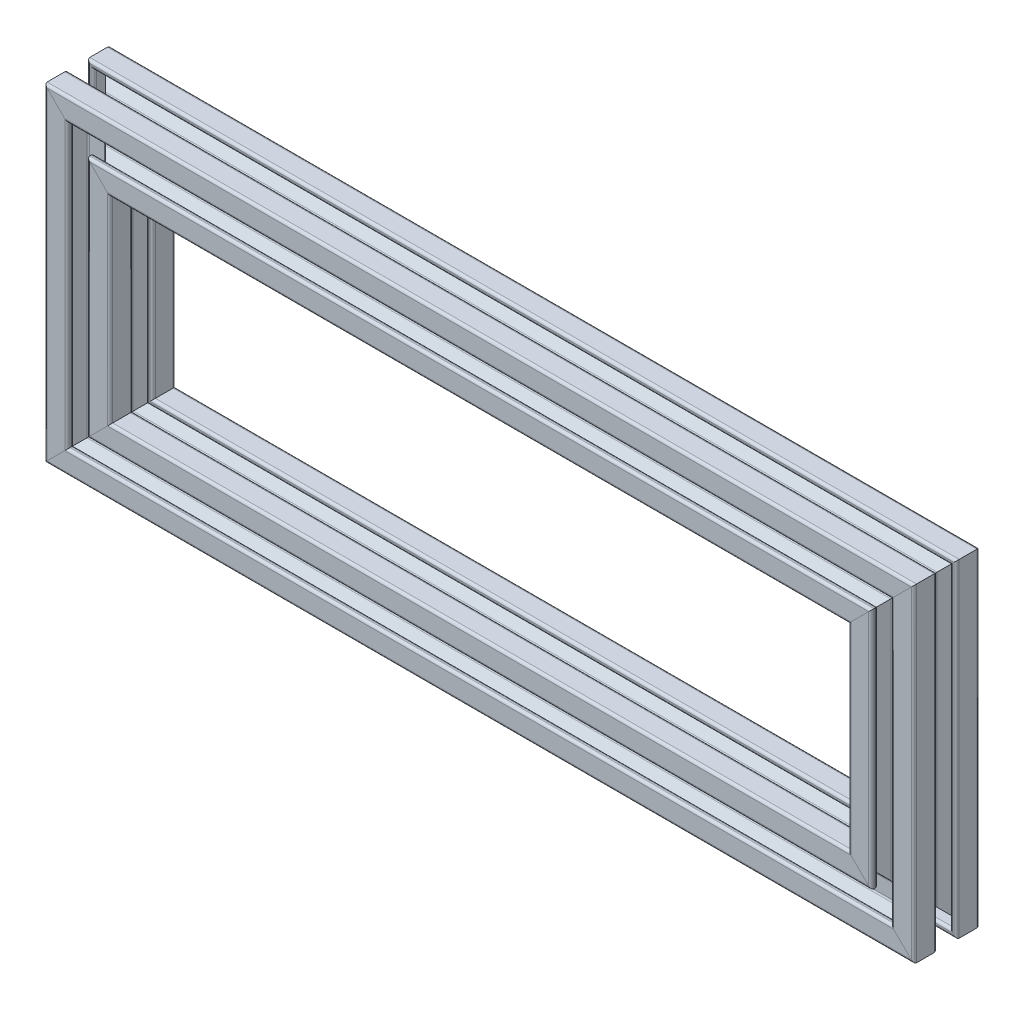
from build123d import *

# Parameters (mm, degrees)
SKETCH1_R               = 2
PROFILE_4X4_1_DEPTH     = 245
SKETCH1_ON_SEGMENT_2_R  = 2
PROFILE_4X4_1_2_DEPTH   = 245
SKETCH11_R              = 2
PROFILE_4X4_2_DEPTH     = 80
SKETCH11_ON_SEGMENT_2_R = 2
PROFILE_4X4_2_2_DEPTH   = 80
BODY_3_RUN_ON_DEPTH     = 10
BODY_2_RUN_ON_DEPTH     = 10
BODY_START              = 80
BODY_3_RUN_ON_2_DEPTH   = 10
PART_RUN_ON_DEPTH       = 10
PART_START              = 245
PART_RUN_ON_2_DEPTH     = 10
BODY_4_RUN_ON_DEPTH     = 10
BODY_START_2            = 245
BODY_2_RUN_ON_2_DEPTH   = 10
BODY_4_RUN_ON_2_DEPTH   = 10


with BuildPart() as part:
    # Sketch1 → Profile 4X4(1) (new body)
    with BuildSketch(Plane(origin=(-122.5, 40, 0), x_dir=(0, 1, 0), z_dir=(1, 0, 0))):
        with BuildLine():
            Line((-3, 9.2), (-3, 8.8))
            ThreePointArc((-3, 8.8), (-3.234314575, 8.234314575), (-3.8, 8))
            Line((-3.8, 8), (-6.585786438, 8))
            Line((-6.585786438, 8), (-2.820101013, 4.234314575))
            ThreePointArc((-2.820101013, 4.234314575), (-2.560562334, 4.060896374), (-2.254415588, 4))
            Line((-2.254415588, 4), (2.254415588, 4))
            ThreePointArc((2.254415588, 4), (2.560562334, 4.060896374), (2.820101013, 4.234314575))
            Line((2.820101013, 4.234314575), (6.585786438, 8))
            Line((6.585786438, 8), (3.8, 8))
            ThreePointArc((3.8, 8), (3.234314575, 8.234314575), (3, 8.8))
            Line((3, 8.8), (3, 9.2))
            ThreePointArc((3, 9.2), (3.234314575, 9.765685425), (3.8, 10))
            Line((3.8, 10), (9.2, 10))
            ThreePointArc((9.2, 10), (9.765685425, 9.765685425), (10, 9.2))
            Line((10, 9.2), (10, 3.8))
            ThreePointArc((10, 3.8), (9.765685425, 3.234314575), (9.2, 3))
            Line((9.2, 3), (8.8, 3))
            ThreePointArc((8.8, 3), (8.234314575, 3.234314575), (8, 3.8))
            Line((8, 3.8), (8, 6.585786438))
            Line((8, 6.585786438), (4.234314575, 2.820101013))
            ThreePointArc((4.234314575, 2.820101013), (4.060896374, 2.560562334), (4, 2.254415588))
            Line((4, 2.254415588), (4, -2.254415588))
            ThreePointArc((4, -2.254415588), (4.060896374, -2.560562334), (4.234314575, -2.820101013))
            Line((4.234314575, -2.820101013), (8, -6.585786438))
            Line((8, -6.585786438), (8, -3.8))
            ThreePointArc((8, -3.8), (8.234314575, -3.234314575), (8.8, -3))
            Line((8.8, -3), (9.2, -3))
            ThreePointArc((9.2, -3), (9.765685425, -3.234314575), (10, -3.8))
            Line((10, -3.8), (10, -9.2))
            ThreePointArc((10, -9.2), (9.765685425, -9.765685425), (9.2, -10))
            Line((9.2, -10), (3.8, -10))
            ThreePointArc((3.8, -10), (3.234314575, -9.765685425), (3, -9.2))
            Line((3, -9.2), (3, -8.8))
            ThreePointArc((3, -8.8), (3.234314575, -8.234314575), (3.8, -8))
            Line((3.8, -8), (6.585786438, -8))
            Line((6.585786438, -8), (2.820101013, -4.234314575))
            ThreePointArc((2.820101013, -4.234314575), (2.560562334, -4.060896374), (2.254415588, -4))
            Line((2.254415588, -4), (-2.254415588, -4))
            ThreePointArc((-2.254415588, -4), (-2.560562334, -4.060896374), (-2.820101013, -4.234314575))
            Line((-2.820101013, -4.234314575), (-6.585786438, -8))
            Line((-6.585786438, -8), (-3.8, -8))
            ThreePointArc((-3.8, -8), (-3.234314575, -8.234314575), (-3, -8.8))
            Line((-3, -8.8), (-3, -9.2))
            ThreePointArc((-3, -9.2), (-3.234314575, -9.765685425), (-3.8, -10))
            Line((-3.8, -10), (-9.2, -10))
            ThreePointArc((-9.2, -10), (-9.765685425, -9.765685425), (-10, -9.2))
            Line((-10, -9.2), (-10, -3.8))
            ThreePointArc((-10, -3.8), (-9.765685425, -3.234314575), (-9.2, -3))
            Line((-9.2, -3), (-8.8, -3))
            ThreePointArc((-8.8, -3), (-8.234314575, -3.234314575), (-8, -3.8))
            Line((-8, -3.8), (-8, -6.585786438))
            Line((-8, -6.585786438), (-4.234314575, -2.820101013))
            ThreePointArc((-4.234314575, -2.820101013), (-4.060896374, -2.560562334), (-4, -2.254415588))
            Line((-4, -2.254415588), (-4, 2.254415588))
            ThreePointArc((-4, 2.254415588), (-4.060896374, 2.560562334), (-4.234314575, 2.820101013))
            Line((-4.234314575, 2.820101013), (-8, 6.585786438))
            Line((-8, 6.585786438), (-8, 3.8))
            ThreePointArc((-8, 3.8), (-8.234314575, 3.234314575), (-8.8, 3))
            Line((-8.8, 3), (-9.2, 3))
            ThreePointArc((-9.2, 3), (-9.765685425, 3.234314575), (-10, 3.8))
            Line((-10, 3.8), (-10, 9.2))
            ThreePointArc((-10, 9.2), (-9.765685425, 9.765685425), (-9.2, 10))
            Line((-9.2, 10), (-3.8, 10))
            ThreePointArc((-3.8, 10), (-3.234314575, 9.765685425), (-3, 9.2))
        make_face()
        Circle(SKETCH1_R, mode=Mode.SUBTRACT)
    extrude(amount=PROFILE_4X4_1_DEPTH)

    # Sketch1 → part run on (add)
    with BuildSketch(Plane(origin=(-122.5, 40, 0), x_dir=(0, 1, 0), z_dir=(1, 0, 0))):
        with BuildLine():
            Line((-3, 9.2), (-3, 8.8))
            ThreePointArc((-3, 8.8), (-3.234314575, 8.234314575), (-3.8, 8))
            Line((-3.8, 8), (-6.585786438, 8))
            Line((-6.585786438, 8), (-2.820101013, 4.234314575))
            ThreePointArc((-2.820101013, 4.234314575), (-2.560562334, 4.060896374), (-2.254415588, 4))
            Line((-2.254415588, 4), (2.254415588, 4))
            ThreePointArc((2.254415588, 4), (2.560562334, 4.060896374), (2.820101013, 4.234314575))
            Line((2.820101013, 4.234314575), (6.585786438, 8))
            Line((6.585786438, 8), (3.8, 8))
            ThreePointArc((3.8, 8), (3.234314575, 8.234314575), (3, 8.8))
            Line((3, 8.8), (3, 9.2))
            ThreePointArc((3, 9.2), (3.234314575, 9.765685425), (3.8, 10))
            Line((3.8, 10), (9.2, 10))
            ThreePointArc((9.2, 10), (9.765685425, 9.765685425), (10, 9.2))
            Line((10, 9.2), (10, 3.8))
            ThreePointArc((10, 3.8), (9.765685425, 3.234314575), (9.2, 3))
            Line((9.2, 3), (8.8, 3))
            ThreePointArc((8.8, 3), (8.234314575, 3.234314575), (8, 3.8))
            Line((8, 3.8), (8, 6.585786438))
            Line((8, 6.585786438), (4.234314575, 2.820101013))
            ThreePointArc((4.234314575, 2.820101013), (4.060896374, 2.560562334), (4, 2.254415588))
            Line((4, 2.254415588), (4, -2.254415588))
            ThreePointArc((4, -2.254415588), (4.060896374, -2.560562334), (4.234314575, -2.820101013))
            Line((4.234314575, -2.820101013), (8, -6.585786438))
            Line((8, -6.585786438), (8, -3.8))
            ThreePointArc((8, -3.8), (8.234314575, -3.234314575), (8.8, -3))
            Line((8.8, -3), (9.2, -3))
            ThreePointArc((9.2, -3), (9.765685425, -3.234314575), (10, -3.8))
            Line((10, -3.8), (10, -9.2))
            ThreePointArc((10, -9.2), (9.765685425, -9.765685425), (9.2, -10))
            Line((9.2, -10), (3.8, -10))
            ThreePointArc((3.8, -10), (3.234314575, -9.765685425), (3, -9.2))
            Line((3, -9.2), (3, -8.8))
            ThreePointArc((3, -8.8), (3.234314575, -8.234314575), (3.8, -8))
            Line((3.8, -8), (6.585786438, -8))
            Line((6.585786438, -8), (2.820101013, -4.234314575))
            ThreePointArc((2.820101013, -4.234314575), (2.560562334, -4.060896374), (2.254415588, -4))
            Line((2.254415588, -4), (-2.254415588, -4))
            ThreePointArc((-2.254415588, -4), (-2.560562334, -4.060896374), (-2.820101013, -4.234314575))
            Line((-2.820101013, -4.234314575), (-6.585786438, -8))
            Line((-6.585786438, -8), (-3.8, -8))
            ThreePointArc((-3.8, -8), (-3.234314575, -8.234314575), (-3, -8.8))
            Line((-3, -8.8), (-3, -9.2))
            ThreePointArc((-3, -9.2), (-3.234314575, -9.765685425), (-3.8, -10))
            Line((-3.8, -10), (-9.2, -10))
            ThreePointArc((-9.2, -10), (-9.765685425, -9.765685425), (-10, -9.2))
            Line((-10, -9.2), (-10, -3.8))
            ThreePointArc((-10, -3.8), (-9.765685425, -3.234314575), (-9.2, -3))
            Line((-9.2, -3), (-8.8, -3))
            ThreePointArc((-8.8, -3), (-8.234314575, -3.234314575), (-8, -3.8))
            Line((-8, -3.8), (-8, -6.585786438))
            Line((-8, -6.585786438), (-4.234314575, -2.820101013))
            ThreePointArc((-4.234314575, -2.820101013), (-4.060896374, -2.560562334), (-4, -2.254415588))
            Line((-4, -2.254415588), (-4, 2.254415588))
            ThreePointArc((-4, 2.254415588), (-4.060896374, 2.560562334), (-4.234314575, 2.820101013))
            Line((-4.234314575, 2.820101013), (-8, 6.585786438))
            Line((-8, 6.585786438), (-8, 3.8))
            ThreePointArc((-8, 3.8), (-8.234314575, 3.234314575), (-8.8, 3))
            Line((-8.8, 3), (-9.2, 3))
            ThreePointArc((-9.2, 3), (-9.765685425, 3.234314575), (-10, 3.8))
            Line((-10, 3.8), (-10, 9.2))
            ThreePointArc((-10, 9.2), (-9.765685425, 9.765685425), (-9.2, 10))
            Line((-9.2, 10), (-3.8, 10))
            ThreePointArc((-3.8, 10), (-3.234314575, 9.765685425), (-3, 9.2))
        make_face()
        Circle(SKETCH1_R, mode=Mode.SUBTRACT)
    extrude(amount=-PART_RUN_ON_DEPTH)

    # Trim/Extend2
    split(bisect_by=Plane(origin=(-122.5, 40, 0), x_dir=(-0.707106781, 0.707106781, 0), z_dir=(0.707106781, 0.707106781, 0)), keep=Keep.TOP)

    # Sketch1 → part run on 2 (add)
    with BuildSketch(Plane(origin=(-122.5, 40, 0), x_dir=(0, 1, 0), z_dir=(1, 0, 0)).offset(PART_START)):
        with BuildLine():
            Line((-3, 9.2), (-3, 8.8))
            ThreePointArc((-3, 8.8), (-3.234314575, 8.234314575), (-3.8, 8))
            Line((-3.8, 8), (-6.585786438, 8))
            Line((-6.585786438, 8), (-2.820101013, 4.234314575))
            ThreePointArc((-2.820101013, 4.234314575), (-2.560562334, 4.060896374), (-2.254415588, 4))
            Line((-2.254415588, 4), (2.254415588, 4))
            ThreePointArc((2.254415588, 4), (2.560562334, 4.060896374), (2.820101013, 4.234314575))
            Line((2.820101013, 4.234314575), (6.585786438, 8))
            Line((6.585786438, 8), (3.8, 8))
            ThreePointArc((3.8, 8), (3.234314575, 8.234314575), (3, 8.8))
            Line((3, 8.8), (3, 9.2))
            ThreePointArc((3, 9.2), (3.234314575, 9.765685425), (3.8, 10))
            Line((3.8, 10), (9.2, 10))
            ThreePointArc((9.2, 10), (9.765685425, 9.765685425), (10, 9.2))
            Line((10, 9.2), (10, 3.8))
            ThreePointArc((10, 3.8), (9.765685425, 3.234314575), (9.2, 3))
            Line((9.2, 3), (8.8, 3))
            ThreePointArc((8.8, 3), (8.234314575, 3.234314575), (8, 3.8))
            Line((8, 3.8), (8, 6.585786438))
            Line((8, 6.585786438), (4.234314575, 2.820101013))
            ThreePointArc((4.234314575, 2.820101013), (4.060896374, 2.560562334), (4, 2.254415588))
            Line((4, 2.254415588), (4, -2.254415588))
            ThreePointArc((4, -2.254415588), (4.060896374, -2.560562334), (4.234314575, -2.820101013))
            Line((4.234314575, -2.820101013), (8, -6.585786438))
            Line((8, -6.585786438), (8, -3.8))
            ThreePointArc((8, -3.8), (8.234314575, -3.234314575), (8.8, -3))
            Line((8.8, -3), (9.2, -3))
            ThreePointArc((9.2, -3), (9.765685425, -3.234314575), (10, -3.8))
            Line((10, -3.8), (10, -9.2))
            ThreePointArc((10, -9.2), (9.765685425, -9.765685425), (9.2, -10))
            Line((9.2, -10), (3.8, -10))
            ThreePointArc((3.8, -10), (3.234314575, -9.765685425), (3, -9.2))
            Line((3, -9.2), (3, -8.8))
            ThreePointArc((3, -8.8), (3.234314575, -8.234314575), (3.8, -8))
            Line((3.8, -8), (6.585786438, -8))
            Line((6.585786438, -8), (2.820101013, -4.234314575))
            ThreePointArc((2.820101013, -4.234314575), (2.560562334, -4.060896374), (2.254415588, -4))
            Line((2.254415588, -4), (-2.254415588, -4))
            ThreePointArc((-2.254415588, -4), (-2.560562334, -4.060896374), (-2.820101013, -4.234314575))
            Line((-2.820101013, -4.234314575), (-6.585786438, -8))
            Line((-6.585786438, -8), (-3.8, -8))
            ThreePointArc((-3.8, -8), (-3.234314575, -8.234314575), (-3, -8.8))
            Line((-3, -8.8), (-3, -9.2))
            ThreePointArc((-3, -9.2), (-3.234314575, -9.765685425), (-3.8, -10))
            Line((-3.8, -10), (-9.2, -10))
            ThreePointArc((-9.2, -10), (-9.765685425, -9.765685425), (-10, -9.2))
            Line((-10, -9.2), (-10, -3.8))
            ThreePointArc((-10, -3.8), (-9.765685425, -3.234314575), (-9.2, -3))
            Line((-9.2, -3), (-8.8, -3))
            ThreePointArc((-8.8, -3), (-8.234314575, -3.234314575), (-8, -3.8))
            Line((-8, -3.8), (-8, -6.585786438))
            Line((-8, -6.585786438), (-4.234314575, -2.820101013))
            ThreePointArc((-4.234314575, -2.820101013), (-4.060896374, -2.560562334), (-4, -2.254415588))
            Line((-4, -2.254415588), (-4, 2.254415588))
            ThreePointArc((-4, 2.254415588), (-4.060896374, 2.560562334), (-4.234314575, 2.820101013))
            Line((-4.234314575, 2.820101013), (-8, 6.585786438))
            Line((-8, 6.585786438), (-8, 3.8))
            ThreePointArc((-8, 3.8), (-8.234314575, 3.234314575), (-8.8, 3))
            Line((-8.8, 3), (-9.2, 3))
            ThreePointArc((-9.2, 3), (-9.765685425, 3.234314575), (-10, 3.8))
            Line((-10, 3.8), (-10, 9.2))
            ThreePointArc((-10, 9.2), (-9.765685425, 9.765685425), (-9.2, 10))
            Line((-9.2, 10), (-3.8, 10))
            ThreePointArc((-3.8, 10), (-3.234314575, 9.765685425), (-3, 9.2))
        make_face()
        Circle(SKETCH1_R, mode=Mode.SUBTRACT)
    extrude(amount=PART_RUN_ON_2_DEPTH)

    # Trim/Extend3
    split(bisect_by=Plane(origin=(122.5, 40, 0), x_dir=(-0.707106781, -0.707106781, 0), z_dir=(-0.707106781, 0.707106781, 0)), keep=Keep.TOP)


with BuildPart() as body_2:
    # Sketch1 on segment 2 (carried to segment 2) → Profile 4X4_1 2 (new body)
    with BuildSketch(Plane(origin=(-122.5, -40, 0), x_dir=(0, 1, 0), z_dir=(1, 0, 0))):
        with BuildLine():
            Line((-3, 9.2), (-3, 8.8))
            ThreePointArc((-3, 8.8), (-3.234314575, 8.234314575), (-3.8, 8))
            Line((-3.8, 8), (-6.585786438, 8))
            Line((-6.585786438, 8), (-2.820101013, 4.234314575))
            ThreePointArc((-2.820101013, 4.234314575), (-2.560562334, 4.060896374), (-2.254415588, 4))
            Line((-2.254415588, 4), (2.254415588, 4))
            ThreePointArc((2.254415588, 4), (2.560562334, 4.060896374), (2.820101013, 4.234314575))
            Line((2.820101013, 4.234314575), (6.585786438, 8))
            Line((6.585786438, 8), (3.8, 8))
            ThreePointArc((3.8, 8), (3.234314575, 8.234314575), (3, 8.8))
            Line((3, 8.8), (3, 9.2))
            ThreePointArc((3, 9.2), (3.234314575, 9.765685425), (3.8, 10))
            Line((3.8, 10), (9.2, 10))
            ThreePointArc((9.2, 10), (9.765685425, 9.765685425), (10, 9.2))
            Line((10, 9.2), (10, 3.8))
            ThreePointArc((10, 3.8), (9.765685425, 3.234314575), (9.2, 3))
            Line((9.2, 3), (8.8, 3))
            ThreePointArc((8.8, 3), (8.234314575, 3.234314575), (8, 3.8))
            Line((8, 3.8), (8, 6.585786438))
            Line((8, 6.585786438), (4.234314575, 2.820101013))
            ThreePointArc((4.234314575, 2.820101013), (4.060896374, 2.560562334), (4, 2.254415588))
            Line((4, 2.254415588), (4, -2.254415588))
            ThreePointArc((4, -2.254415588), (4.060896374, -2.560562334), (4.234314575, -2.820101013))
            Line((4.234314575, -2.820101013), (8, -6.585786438))
            Line((8, -6.585786438), (8, -3.8))
            ThreePointArc((8, -3.8), (8.234314575, -3.234314575), (8.8, -3))
            Line((8.8, -3), (9.2, -3))
            ThreePointArc((9.2, -3), (9.765685425, -3.234314575), (10, -3.8))
            Line((10, -3.8), (10, -9.2))
            ThreePointArc((10, -9.2), (9.765685425, -9.765685425), (9.2, -10))
            Line((9.2, -10), (3.8, -10))
            ThreePointArc((3.8, -10), (3.234314575, -9.765685425), (3, -9.2))
            Line((3, -9.2), (3, -8.8))
            ThreePointArc((3, -8.8), (3.234314575, -8.234314575), (3.8, -8))
            Line((3.8, -8), (6.585786438, -8))
            Line((6.585786438, -8), (2.820101013, -4.234314575))
            ThreePointArc((2.820101013, -4.234314575), (2.560562334, -4.060896374), (2.254415588, -4))
            Line((2.254415588, -4), (-2.254415588, -4))
            ThreePointArc((-2.254415588, -4), (-2.560562334, -4.060896374), (-2.820101013, -4.234314575))
            Line((-2.820101013, -4.234314575), (-6.585786438, -8))
            Line((-6.585786438, -8), (-3.8, -8))
            ThreePointArc((-3.8, -8), (-3.234314575, -8.234314575), (-3, -8.8))
            Line((-3, -8.8), (-3, -9.2))
            ThreePointArc((-3, -9.2), (-3.234314575, -9.765685425), (-3.8, -10))
            Line((-3.8, -10), (-9.2, -10))
            ThreePointArc((-9.2, -10), (-9.765685425, -9.765685425), (-10, -9.2))
            Line((-10, -9.2), (-10, -3.8))
            ThreePointArc((-10, -3.8), (-9.765685425, -3.234314575), (-9.2, -3))
            Line((-9.2, -3), (-8.8, -3))
            ThreePointArc((-8.8, -3), (-8.234314575, -3.234314575), (-8, -3.8))
            Line((-8, -3.8), (-8, -6.585786438))
            Line((-8, -6.585786438), (-4.234314575, -2.820101013))
            ThreePointArc((-4.234314575, -2.820101013), (-4.060896374, -2.560562334), (-4, -2.254415588))
            Line((-4, -2.254415588), (-4, 2.254415588))
            ThreePointArc((-4, 2.254415588), (-4.060896374, 2.560562334), (-4.234314575, 2.820101013))
            Line((-4.234314575, 2.820101013), (-8, 6.585786438))
            Line((-8, 6.585786438), (-8, 3.8))
            ThreePointArc((-8, 3.8), (-8.234314575, 3.234314575), (-8.8, 3))
            Line((-8.8, 3), (-9.2, 3))
            ThreePointArc((-9.2, 3), (-9.765685425, 3.234314575), (-10, 3.8))
            Line((-10, 3.8), (-10, 9.2))
            ThreePointArc((-10, 9.2), (-9.765685425, 9.765685425), (-9.2, 10))
            Line((-9.2, 10), (-3.8, 10))
            ThreePointArc((-3.8, 10), (-3.234314575, 9.765685425), (-3, 9.2))
        make_face()
        Circle(SKETCH1_ON_SEGMENT_2_R, mode=Mode.SUBTRACT)
    extrude(amount=PROFILE_4X4_1_2_DEPTH)

    # Sketch1 on segment 2 (carried to segment 2) → body 2 run on (add)
    with BuildSketch(Plane(origin=(-122.5, -40, 0), x_dir=(0, 1, 0), z_dir=(1, 0, 0))):
        with BuildLine():
            Line((-3, 9.2), (-3, 8.8))
            ThreePointArc((-3, 8.8), (-3.234314575, 8.234314575), (-3.8, 8))
            Line((-3.8, 8), (-6.585786438, 8))
            Line((-6.585786438, 8), (-2.820101013, 4.234314575))
            ThreePointArc((-2.820101013, 4.234314575), (-2.560562334, 4.060896374), (-2.254415588, 4))
            Line((-2.254415588, 4), (2.254415588, 4))
            ThreePointArc((2.254415588, 4), (2.560562334, 4.060896374), (2.820101013, 4.234314575))
            Line((2.820101013, 4.234314575), (6.585786438, 8))
            Line((6.585786438, 8), (3.8, 8))
            ThreePointArc((3.8, 8), (3.234314575, 8.234314575), (3, 8.8))
            Line((3, 8.8), (3, 9.2))
            ThreePointArc((3, 9.2), (3.234314575, 9.765685425), (3.8, 10))
            Line((3.8, 10), (9.2, 10))
            ThreePointArc((9.2, 10), (9.765685425, 9.765685425), (10, 9.2))
            Line((10, 9.2), (10, 3.8))
            ThreePointArc((10, 3.8), (9.765685425, 3.234314575), (9.2, 3))
            Line((9.2, 3), (8.8, 3))
            ThreePointArc((8.8, 3), (8.234314575, 3.234314575), (8, 3.8))
            Line((8, 3.8), (8, 6.585786438))
            Line((8, 6.585786438), (4.234314575, 2.820101013))
            ThreePointArc((4.234314575, 2.820101013), (4.060896374, 2.560562334), (4, 2.254415588))
            Line((4, 2.254415588), (4, -2.254415588))
            ThreePointArc((4, -2.254415588), (4.060896374, -2.560562334), (4.234314575, -2.820101013))
            Line((4.234314575, -2.820101013), (8, -6.585786438))
            Line((8, -6.585786438), (8, -3.8))
            ThreePointArc((8, -3.8), (8.234314575, -3.234314575), (8.8, -3))
            Line((8.8, -3), (9.2, -3))
            ThreePointArc((9.2, -3), (9.765685425, -3.234314575), (10, -3.8))
            Line((10, -3.8), (10, -9.2))
            ThreePointArc((10, -9.2), (9.765685425, -9.765685425), (9.2, -10))
            Line((9.2, -10), (3.8, -10))
            ThreePointArc((3.8, -10), (3.234314575, -9.765685425), (3, -9.2))
            Line((3, -9.2), (3, -8.8))
            ThreePointArc((3, -8.8), (3.234314575, -8.234314575), (3.8, -8))
            Line((3.8, -8), (6.585786438, -8))
            Line((6.585786438, -8), (2.820101013, -4.234314575))
            ThreePointArc((2.820101013, -4.234314575), (2.560562334, -4.060896374), (2.254415588, -4))
            Line((2.254415588, -4), (-2.254415588, -4))
            ThreePointArc((-2.254415588, -4), (-2.560562334, -4.060896374), (-2.820101013, -4.234314575))
            Line((-2.820101013, -4.234314575), (-6.585786438, -8))
            Line((-6.585786438, -8), (-3.8, -8))
            ThreePointArc((-3.8, -8), (-3.234314575, -8.234314575), (-3, -8.8))
            Line((-3, -8.8), (-3, -9.2))
            ThreePointArc((-3, -9.2), (-3.234314575, -9.765685425), (-3.8, -10))
            Line((-3.8, -10), (-9.2, -10))
            ThreePointArc((-9.2, -10), (-9.765685425, -9.765685425), (-10, -9.2))
            Line((-10, -9.2), (-10, -3.8))
            ThreePointArc((-10, -3.8), (-9.765685425, -3.234314575), (-9.2, -3))
            Line((-9.2, -3), (-8.8, -3))
            ThreePointArc((-8.8, -3), (-8.234314575, -3.234314575), (-8, -3.8))
            Line((-8, -3.8), (-8, -6.585786438))
            Line((-8, -6.585786438), (-4.234314575, -2.820101013))
            ThreePointArc((-4.234314575, -2.820101013), (-4.060896374, -2.560562334), (-4, -2.254415588))
            Line((-4, -2.254415588), (-4, 2.254415588))
            ThreePointArc((-4, 2.254415588), (-4.060896374, 2.560562334), (-4.234314575, 2.820101013))
            Line((-4.234314575, 2.820101013), (-8, 6.585786438))
            Line((-8, 6.585786438), (-8, 3.8))
            ThreePointArc((-8, 3.8), (-8.234314575, 3.234314575), (-8.8, 3))
            Line((-8.8, 3), (-9.2, 3))
            ThreePointArc((-9.2, 3), (-9.765685425, 3.234314575), (-10, 3.8))
            Line((-10, 3.8), (-10, 9.2))
            ThreePointArc((-10, 9.2), (-9.765685425, 9.765685425), (-9.2, 10))
            Line((-9.2, 10), (-3.8, 10))
            ThreePointArc((-3.8, 10), (-3.234314575, 9.765685425), (-3, 9.2))
        make_face()
        Circle(SKETCH1_ON_SEGMENT_2_R, mode=Mode.SUBTRACT)
    extrude(amount=-BODY_2_RUN_ON_DEPTH)

    # Trim/Extend1
    split(bisect_by=Plane(origin=(-122.5, -40, 0), x_dir=(0.707106781, 0.707106781, 0), z_dir=(0.707106781, -0.707106781, 0)), keep=Keep.TOP)

    # Sketch1 on segment 2 (carried to segment 2) → body 2 run on 2 (add)
    with BuildSketch(Plane(origin=(-122.5, -40, 0), x_dir=(0, 1, 0), z_dir=(1, 0, 0)).offset(BODY_START_2)):
        with BuildLine():
            Line((-3, 9.2), (-3, 8.8))
            ThreePointArc((-3, 8.8), (-3.234314575, 8.234314575), (-3.8, 8))
            Line((-3.8, 8), (-6.585786438, 8))
            Line((-6.585786438, 8), (-2.820101013, 4.234314575))
            ThreePointArc((-2.820101013, 4.234314575), (-2.560562334, 4.060896374), (-2.254415588, 4))
            Line((-2.254415588, 4), (2.254415588, 4))
            ThreePointArc((2.254415588, 4), (2.560562334, 4.060896374), (2.820101013, 4.234314575))
            Line((2.820101013, 4.234314575), (6.585786438, 8))
            Line((6.585786438, 8), (3.8, 8))
            ThreePointArc((3.8, 8), (3.234314575, 8.234314575), (3, 8.8))
            Line((3, 8.8), (3, 9.2))
            ThreePointArc((3, 9.2), (3.234314575, 9.765685425), (3.8, 10))
            Line((3.8, 10), (9.2, 10))
            ThreePointArc((9.2, 10), (9.765685425, 9.765685425), (10, 9.2))
            Line((10, 9.2), (10, 3.8))
            ThreePointArc((10, 3.8), (9.765685425, 3.234314575), (9.2, 3))
            Line((9.2, 3), (8.8, 3))
            ThreePointArc((8.8, 3), (8.234314575, 3.234314575), (8, 3.8))
            Line((8, 3.8), (8, 6.585786438))
            Line((8, 6.585786438), (4.234314575, 2.820101013))
            ThreePointArc((4.234314575, 2.820101013), (4.060896374, 2.560562334), (4, 2.254415588))
            Line((4, 2.254415588), (4, -2.254415588))
            ThreePointArc((4, -2.254415588), (4.060896374, -2.560562334), (4.234314575, -2.820101013))
            Line((4.234314575, -2.820101013), (8, -6.585786438))
            Line((8, -6.585786438), (8, -3.8))
            ThreePointArc((8, -3.8), (8.234314575, -3.234314575), (8.8, -3))
            Line((8.8, -3), (9.2, -3))
            ThreePointArc((9.2, -3), (9.765685425, -3.234314575), (10, -3.8))
            Line((10, -3.8), (10, -9.2))
            ThreePointArc((10, -9.2), (9.765685425, -9.765685425), (9.2, -10))
            Line((9.2, -10), (3.8, -10))
            ThreePointArc((3.8, -10), (3.234314575, -9.765685425), (3, -9.2))
            Line((3, -9.2), (3, -8.8))
            ThreePointArc((3, -8.8), (3.234314575, -8.234314575), (3.8, -8))
            Line((3.8, -8), (6.585786438, -8))
            Line((6.585786438, -8), (2.820101013, -4.234314575))
            ThreePointArc((2.820101013, -4.234314575), (2.560562334, -4.060896374), (2.254415588, -4))
            Line((2.254415588, -4), (-2.254415588, -4))
            ThreePointArc((-2.254415588, -4), (-2.560562334, -4.060896374), (-2.820101013, -4.234314575))
            Line((-2.820101013, -4.234314575), (-6.585786438, -8))
            Line((-6.585786438, -8), (-3.8, -8))
            ThreePointArc((-3.8, -8), (-3.234314575, -8.234314575), (-3, -8.8))
            Line((-3, -8.8), (-3, -9.2))
            ThreePointArc((-3, -9.2), (-3.234314575, -9.765685425), (-3.8, -10))
            Line((-3.8, -10), (-9.2, -10))
            ThreePointArc((-9.2, -10), (-9.765685425, -9.765685425), (-10, -9.2))
            Line((-10, -9.2), (-10, -3.8))
            ThreePointArc((-10, -3.8), (-9.765685425, -3.234314575), (-9.2, -3))
            Line((-9.2, -3), (-8.8, -3))
            ThreePointArc((-8.8, -3), (-8.234314575, -3.234314575), (-8, -3.8))
            Line((-8, -3.8), (-8, -6.585786438))
            Line((-8, -6.585786438), (-4.234314575, -2.820101013))
            ThreePointArc((-4.234314575, -2.820101013), (-4.060896374, -2.560562334), (-4, -2.254415588))
            Line((-4, -2.254415588), (-4, 2.254415588))
            ThreePointArc((-4, 2.254415588), (-4.060896374, 2.560562334), (-4.234314575, 2.820101013))
            Line((-4.234314575, 2.820101013), (-8, 6.585786438))
            Line((-8, 6.585786438), (-8, 3.8))
            ThreePointArc((-8, 3.8), (-8.234314575, 3.234314575), (-8.8, 3))
            Line((-8.8, 3), (-9.2, 3))
            ThreePointArc((-9.2, 3), (-9.765685425, 3.234314575), (-10, 3.8))
            Line((-10, 3.8), (-10, 9.2))
            ThreePointArc((-10, 9.2), (-9.765685425, 9.765685425), (-9.2, 10))
            Line((-9.2, 10), (-3.8, 10))
            ThreePointArc((-3.8, 10), (-3.234314575, 9.765685425), (-3, 9.2))
        make_face()
        Circle(SKETCH1_ON_SEGMENT_2_R, mode=Mode.SUBTRACT)
    extrude(amount=BODY_2_RUN_ON_2_DEPTH)

    # Trim/Extend4
    split(bisect_by=Plane(origin=(122.5, -40, 0), x_dir=(0.707106781, -0.707106781, 0), z_dir=(-0.707106781, -0.707106781, 0)), keep=Keep.TOP)


with BuildPart() as body_3:
    # Sketch11 → Profile 4X4(2) (new body)
    with BuildSketch(Plane(origin=(-122.5, -40, 0), x_dir=(-1, 0, 0), z_dir=(0, 1, 0))):
        with BuildLine():
            Line((-3, 9.2), (-3, 8.8))
            ThreePointArc((-3, 8.8), (-3.234314575, 8.234314575), (-3.8, 8))
            Line((-3.8, 8), (-6.585786438, 8))
            Line((-6.585786438, 8), (-2.820101013, 4.234314575))
            ThreePointArc((-2.820101013, 4.234314575), (-2.560562334, 4.060896374), (-2.254415588, 4))
            Line((-2.254415588, 4), (2.254415588, 4))
            ThreePointArc((2.254415588, 4), (2.560562334, 4.060896374), (2.820101013, 4.234314575))
            Line((2.820101013, 4.234314575), (6.585786438, 8))
            Line((6.585786438, 8), (3.8, 8))
            ThreePointArc((3.8, 8), (3.234314575, 8.234314575), (3, 8.8))
            Line((3, 8.8), (3, 9.2))
            ThreePointArc((3, 9.2), (3.234314575, 9.765685425), (3.8, 10))
            Line((3.8, 10), (9.2, 10))
            ThreePointArc((9.2, 10), (9.765685425, 9.765685425), (10, 9.2))
            Line((10, 9.2), (10, 3.8))
            ThreePointArc((10, 3.8), (9.765685425, 3.234314575), (9.2, 3))
            Line((9.2, 3), (8.8, 3))
            ThreePointArc((8.8, 3), (8.234314575, 3.234314575), (8, 3.8))
            Line((8, 3.8), (8, 6.585786438))
            Line((8, 6.585786438), (4.234314575, 2.820101013))
            ThreePointArc((4.234314575, 2.820101013), (4.060896374, 2.560562334), (4, 2.254415588))
            Line((4, 2.254415588), (4, -2.254415588))
            ThreePointArc((4, -2.254415588), (4.060896374, -2.560562334), (4.234314575, -2.820101013))
            Line((4.234314575, -2.820101013), (8, -6.585786438))
            Line((8, -6.585786438), (8, -3.8))
            ThreePointArc((8, -3.8), (8.234314575, -3.234314575), (8.8, -3))
            Line((8.8, -3), (9.2, -3))
            ThreePointArc((9.2, -3), (9.765685425, -3.234314575), (10, -3.8))
            Line((10, -3.8), (10, -9.2))
            ThreePointArc((10, -9.2), (9.765685425, -9.765685425), (9.2, -10))
            Line((9.2, -10), (3.8, -10))
            ThreePointArc((3.8, -10), (3.234314575, -9.765685425), (3, -9.2))
            Line((3, -9.2), (3, -8.8))
            ThreePointArc((3, -8.8), (3.234314575, -8.234314575), (3.8, -8))
            Line((3.8, -8), (6.585786438, -8))
            Line((6.585786438, -8), (2.820101013, -4.234314575))
            ThreePointArc((2.820101013, -4.234314575), (2.560562334, -4.060896374), (2.254415588, -4))
            Line((2.254415588, -4), (-2.254415588, -4))
            ThreePointArc((-2.254415588, -4), (-2.560562334, -4.060896374), (-2.820101013, -4.234314575))
            Line((-2.820101013, -4.234314575), (-6.585786438, -8))
            Line((-6.585786438, -8), (-3.8, -8))
            ThreePointArc((-3.8, -8), (-3.234314575, -8.234314575), (-3, -8.8))
            Line((-3, -8.8), (-3, -9.2))
            ThreePointArc((-3, -9.2), (-3.234314575, -9.765685425), (-3.8, -10))
            Line((-3.8, -10), (-9.2, -10))
            ThreePointArc((-9.2, -10), (-9.765685425, -9.765685425), (-10, -9.2))
            Line((-10, -9.2), (-10, -3.8))
            ThreePointArc((-10, -3.8), (-9.765685425, -3.234314575), (-9.2, -3))
            Line((-9.2, -3), (-8.8, -3))
            ThreePointArc((-8.8, -3), (-8.234314575, -3.234314575), (-8, -3.8))
            Line((-8, -3.8), (-8, -6.585786438))
            Line((-8, -6.585786438), (-4.234314575, -2.820101013))
            ThreePointArc((-4.234314575, -2.820101013), (-4.060896374, -2.560562334), (-4, -2.254415588))
            Line((-4, -2.254415588), (-4, 2.254415588))
            ThreePointArc((-4, 2.254415588), (-4.060896374, 2.560562334), (-4.234314575, 2.820101013))
            Line((-4.234314575, 2.820101013), (-8, 6.585786438))
            Line((-8, 6.585786438), (-8, 3.8))
            ThreePointArc((-8, 3.8), (-8.234314575, 3.234314575), (-8.8, 3))
            Line((-8.8, 3), (-9.2, 3))
            ThreePointArc((-9.2, 3), (-9.765685425, 3.234314575), (-10, 3.8))
            Line((-10, 3.8), (-10, 9.2))
            ThreePointArc((-10, 9.2), (-9.765685425, 9.765685425), (-9.2, 10))
            Line((-9.2, 10), (-3.8, 10))
            ThreePointArc((-3.8, 10), (-3.234314575, 9.765685425), (-3, 9.2))
        make_face()
        Circle(SKETCH11_R, mode=Mode.SUBTRACT)
    extrude(amount=PROFILE_4X4_2_DEPTH)

    # Sketch11 → body 3 run on (add)
    with BuildSketch(Plane(origin=(-122.5, -40, 0), x_dir=(-1, 0, 0), z_dir=(0, 1, 0))):
        with BuildLine():
            Line((-3, 9.2), (-3, 8.8))
            ThreePointArc((-3, 8.8), (-3.234314575, 8.234314575), (-3.8, 8))
            Line((-3.8, 8), (-6.585786438, 8))
            Line((-6.585786438, 8), (-2.820101013, 4.234314575))
            ThreePointArc((-2.820101013, 4.234314575), (-2.560562334, 4.060896374), (-2.254415588, 4))
            Line((-2.254415588, 4), (2.254415588, 4))
            ThreePointArc((2.254415588, 4), (2.560562334, 4.060896374), (2.820101013, 4.234314575))
            Line((2.820101013, 4.234314575), (6.585786438, 8))
            Line((6.585786438, 8), (3.8, 8))
            ThreePointArc((3.8, 8), (3.234314575, 8.234314575), (3, 8.8))
            Line((3, 8.8), (3, 9.2))
            ThreePointArc((3, 9.2), (3.234314575, 9.765685425), (3.8, 10))
            Line((3.8, 10), (9.2, 10))
            ThreePointArc((9.2, 10), (9.765685425, 9.765685425), (10, 9.2))
            Line((10, 9.2), (10, 3.8))
            ThreePointArc((10, 3.8), (9.765685425, 3.234314575), (9.2, 3))
            Line((9.2, 3), (8.8, 3))
            ThreePointArc((8.8, 3), (8.234314575, 3.234314575), (8, 3.8))
            Line((8, 3.8), (8, 6.585786438))
            Line((8, 6.585786438), (4.234314575, 2.820101013))
            ThreePointArc((4.234314575, 2.820101013), (4.060896374, 2.560562334), (4, 2.254415588))
            Line((4, 2.254415588), (4, -2.254415588))
            ThreePointArc((4, -2.254415588), (4.060896374, -2.560562334), (4.234314575, -2.820101013))
            Line((4.234314575, -2.820101013), (8, -6.585786438))
            Line((8, -6.585786438), (8, -3.8))
            ThreePointArc((8, -3.8), (8.234314575, -3.234314575), (8.8, -3))
            Line((8.8, -3), (9.2, -3))
            ThreePointArc((9.2, -3), (9.765685425, -3.234314575), (10, -3.8))
            Line((10, -3.8), (10, -9.2))
            ThreePointArc((10, -9.2), (9.765685425, -9.765685425), (9.2, -10))
            Line((9.2, -10), (3.8, -10))
            ThreePointArc((3.8, -10), (3.234314575, -9.765685425), (3, -9.2))
            Line((3, -9.2), (3, -8.8))
            ThreePointArc((3, -8.8), (3.234314575, -8.234314575), (3.8, -8))
            Line((3.8, -8), (6.585786438, -8))
            Line((6.585786438, -8), (2.820101013, -4.234314575))
            ThreePointArc((2.820101013, -4.234314575), (2.560562334, -4.060896374), (2.254415588, -4))
            Line((2.254415588, -4), (-2.254415588, -4))
            ThreePointArc((-2.254415588, -4), (-2.560562334, -4.060896374), (-2.820101013, -4.234314575))
            Line((-2.820101013, -4.234314575), (-6.585786438, -8))
            Line((-6.585786438, -8), (-3.8, -8))
            ThreePointArc((-3.8, -8), (-3.234314575, -8.234314575), (-3, -8.8))
            Line((-3, -8.8), (-3, -9.2))
            ThreePointArc((-3, -9.2), (-3.234314575, -9.765685425), (-3.8, -10))
            Line((-3.8, -10), (-9.2, -10))
            ThreePointArc((-9.2, -10), (-9.765685425, -9.765685425), (-10, -9.2))
            Line((-10, -9.2), (-10, -3.8))
            ThreePointArc((-10, -3.8), (-9.765685425, -3.234314575), (-9.2, -3))
            Line((-9.2, -3), (-8.8, -3))
            ThreePointArc((-8.8, -3), (-8.234314575, -3.234314575), (-8, -3.8))
            Line((-8, -3.8), (-8, -6.585786438))
            Line((-8, -6.585786438), (-4.234314575, -2.820101013))
            ThreePointArc((-4.234314575, -2.820101013), (-4.060896374, -2.560562334), (-4, -2.254415588))
            Line((-4, -2.254415588), (-4, 2.254415588))
            ThreePointArc((-4, 2.254415588), (-4.060896374, 2.560562334), (-4.234314575, 2.820101013))
            Line((-4.234314575, 2.820101013), (-8, 6.585786438))
            Line((-8, 6.585786438), (-8, 3.8))
            ThreePointArc((-8, 3.8), (-8.234314575, 3.234314575), (-8.8, 3))
            Line((-8.8, 3), (-9.2, 3))
            ThreePointArc((-9.2, 3), (-9.765685425, 3.234314575), (-10, 3.8))
            Line((-10, 3.8), (-10, 9.2))
            ThreePointArc((-10, 9.2), (-9.765685425, 9.765685425), (-9.2, 10))
            Line((-9.2, 10), (-3.8, 10))
            ThreePointArc((-3.8, 10), (-3.234314575, 9.765685425), (-3, 9.2))
        make_face()
        Circle(SKETCH11_R, mode=Mode.SUBTRACT)
    extrude(amount=-BODY_3_RUN_ON_DEPTH)

    # Trim/Extend1
    split(bisect_by=Plane(origin=(-122.5, -40, 0), x_dir=(-0.707106781, -0.707106781, 0), z_dir=(-0.707106781, 0.707106781, 0)), keep=Keep.TOP)

    # Sketch11 → body 3 run on 2 (add)
    with BuildSketch(Plane(origin=(-122.5, -40, 0), x_dir=(-1, 0, 0), z_dir=(0, 1, 0)).offset(BODY_START)):
        with BuildLine():
            Line((-3, 9.2), (-3, 8.8))
            ThreePointArc((-3, 8.8), (-3.234314575, 8.234314575), (-3.8, 8))
            Line((-3.8, 8), (-6.585786438, 8))
            Line((-6.585786438, 8), (-2.820101013, 4.234314575))
            ThreePointArc((-2.820101013, 4.234314575), (-2.560562334, 4.060896374), (-2.254415588, 4))
            Line((-2.254415588, 4), (2.254415588, 4))
            ThreePointArc((2.254415588, 4), (2.560562334, 4.060896374), (2.820101013, 4.234314575))
            Line((2.820101013, 4.234314575), (6.585786438, 8))
            Line((6.585786438, 8), (3.8, 8))
            ThreePointArc((3.8, 8), (3.234314575, 8.234314575), (3, 8.8))
            Line((3, 8.8), (3, 9.2))
            ThreePointArc((3, 9.2), (3.234314575, 9.765685425), (3.8, 10))
            Line((3.8, 10), (9.2, 10))
            ThreePointArc((9.2, 10), (9.765685425, 9.765685425), (10, 9.2))
            Line((10, 9.2), (10, 3.8))
            ThreePointArc((10, 3.8), (9.765685425, 3.234314575), (9.2, 3))
            Line((9.2, 3), (8.8, 3))
            ThreePointArc((8.8, 3), (8.234314575, 3.234314575), (8, 3.8))
            Line((8, 3.8), (8, 6.585786438))
            Line((8, 6.585786438), (4.234314575, 2.820101013))
            ThreePointArc((4.234314575, 2.820101013), (4.060896374, 2.560562334), (4, 2.254415588))
            Line((4, 2.254415588), (4, -2.254415588))
            ThreePointArc((4, -2.254415588), (4.060896374, -2.560562334), (4.234314575, -2.820101013))
            Line((4.234314575, -2.820101013), (8, -6.585786438))
            Line((8, -6.585786438), (8, -3.8))
            ThreePointArc((8, -3.8), (8.234314575, -3.234314575), (8.8, -3))
            Line((8.8, -3), (9.2, -3))
            ThreePointArc((9.2, -3), (9.765685425, -3.234314575), (10, -3.8))
            Line((10, -3.8), (10, -9.2))
            ThreePointArc((10, -9.2), (9.765685425, -9.765685425), (9.2, -10))
            Line((9.2, -10), (3.8, -10))
            ThreePointArc((3.8, -10), (3.234314575, -9.765685425), (3, -9.2))
            Line((3, -9.2), (3, -8.8))
            ThreePointArc((3, -8.8), (3.234314575, -8.234314575), (3.8, -8))
            Line((3.8, -8), (6.585786438, -8))
            Line((6.585786438, -8), (2.820101013, -4.234314575))
            ThreePointArc((2.820101013, -4.234314575), (2.560562334, -4.060896374), (2.254415588, -4))
            Line((2.254415588, -4), (-2.254415588, -4))
            ThreePointArc((-2.254415588, -4), (-2.560562334, -4.060896374), (-2.820101013, -4.234314575))
            Line((-2.820101013, -4.234314575), (-6.585786438, -8))
            Line((-6.585786438, -8), (-3.8, -8))
            ThreePointArc((-3.8, -8), (-3.234314575, -8.234314575), (-3, -8.8))
            Line((-3, -8.8), (-3, -9.2))
            ThreePointArc((-3, -9.2), (-3.234314575, -9.765685425), (-3.8, -10))
            Line((-3.8, -10), (-9.2, -10))
            ThreePointArc((-9.2, -10), (-9.765685425, -9.765685425), (-10, -9.2))
            Line((-10, -9.2), (-10, -3.8))
            ThreePointArc((-10, -3.8), (-9.765685425, -3.234314575), (-9.2, -3))
            Line((-9.2, -3), (-8.8, -3))
            ThreePointArc((-8.8, -3), (-8.234314575, -3.234314575), (-8, -3.8))
            Line((-8, -3.8), (-8, -6.585786438))
            Line((-8, -6.585786438), (-4.234314575, -2.820101013))
            ThreePointArc((-4.234314575, -2.820101013), (-4.060896374, -2.560562334), (-4, -2.254415588))
            Line((-4, -2.254415588), (-4, 2.254415588))
            ThreePointArc((-4, 2.254415588), (-4.060896374, 2.560562334), (-4.234314575, 2.820101013))
            Line((-4.234314575, 2.820101013), (-8, 6.585786438))
            Line((-8, 6.585786438), (-8, 3.8))
            ThreePointArc((-8, 3.8), (-8.234314575, 3.234314575), (-8.8, 3))
            Line((-8.8, 3), (-9.2, 3))
            ThreePointArc((-9.2, 3), (-9.765685425, 3.234314575), (-10, 3.8))
            Line((-10, 3.8), (-10, 9.2))
            ThreePointArc((-10, 9.2), (-9.765685425, 9.765685425), (-9.2, 10))
            Line((-9.2, 10), (-3.8, 10))
            ThreePointArc((-3.8, 10), (-3.234314575, 9.765685425), (-3, 9.2))
        make_face()
        Circle(SKETCH11_R, mode=Mode.SUBTRACT)
    extrude(amount=BODY_3_RUN_ON_2_DEPTH)

    # Trim/Extend2
    split(bisect_by=Plane(origin=(-122.5, 40, 0), x_dir=(0.707106781, -0.707106781, 0), z_dir=(-0.707106781, -0.707106781, 0)), keep=Keep.TOP)


with BuildPart() as body_4:
    # Sketch11 on segment 2 (carried to segment 2) → Profile 4X4_2 2 (new body)
    with BuildSketch(Plane(origin=(122.5, -40, 0), x_dir=(-1, 0, 0), z_dir=(0, 1, 0))):
        with BuildLine():
            Line((-3, 9.2), (-3, 8.8))
            ThreePointArc((-3, 8.8), (-3.234314575, 8.234314575), (-3.8, 8))
            Line((-3.8, 8), (-6.585786438, 8))
            Line((-6.585786438, 8), (-2.820101013, 4.234314575))
            ThreePointArc((-2.820101013, 4.234314575), (-2.560562334, 4.060896374), (-2.254415588, 4))
            Line((-2.254415588, 4), (2.254415588, 4))
            ThreePointArc((2.254415588, 4), (2.560562334, 4.060896374), (2.820101013, 4.234314575))
            Line((2.820101013, 4.234314575), (6.585786438, 8))
            Line((6.585786438, 8), (3.8, 8))
            ThreePointArc((3.8, 8), (3.234314575, 8.234314575), (3, 8.8))
            Line((3, 8.8), (3, 9.2))
            ThreePointArc((3, 9.2), (3.234314575, 9.765685425), (3.8, 10))
            Line((3.8, 10), (9.2, 10))
            ThreePointArc((9.2, 10), (9.765685425, 9.765685425), (10, 9.2))
            Line((10, 9.2), (10, 3.8))
            ThreePointArc((10, 3.8), (9.765685425, 3.234314575), (9.2, 3))
            Line((9.2, 3), (8.8, 3))
            ThreePointArc((8.8, 3), (8.234314575, 3.234314575), (8, 3.8))
            Line((8, 3.8), (8, 6.585786438))
            Line((8, 6.585786438), (4.234314575, 2.820101013))
            ThreePointArc((4.234314575, 2.820101013), (4.060896374, 2.560562334), (4, 2.254415588))
            Line((4, 2.254415588), (4, -2.254415588))
            ThreePointArc((4, -2.254415588), (4.060896374, -2.560562334), (4.234314575, -2.820101013))
            Line((4.234314575, -2.820101013), (8, -6.585786438))
            Line((8, -6.585786438), (8, -3.8))
            ThreePointArc((8, -3.8), (8.234314575, -3.234314575), (8.8, -3))
            Line((8.8, -3), (9.2, -3))
            ThreePointArc((9.2, -3), (9.765685425, -3.234314575), (10, -3.8))
            Line((10, -3.8), (10, -9.2))
            ThreePointArc((10, -9.2), (9.765685425, -9.765685425), (9.2, -10))
            Line((9.2, -10), (3.8, -10))
            ThreePointArc((3.8, -10), (3.234314575, -9.765685425), (3, -9.2))
            Line((3, -9.2), (3, -8.8))
            ThreePointArc((3, -8.8), (3.234314575, -8.234314575), (3.8, -8))
            Line((3.8, -8), (6.585786438, -8))
            Line((6.585786438, -8), (2.820101013, -4.234314575))
            ThreePointArc((2.820101013, -4.234314575), (2.560562334, -4.060896374), (2.254415588, -4))
            Line((2.254415588, -4), (-2.254415588, -4))
            ThreePointArc((-2.254415588, -4), (-2.560562334, -4.060896374), (-2.820101013, -4.234314575))
            Line((-2.820101013, -4.234314575), (-6.585786438, -8))
            Line((-6.585786438, -8), (-3.8, -8))
            ThreePointArc((-3.8, -8), (-3.234314575, -8.234314575), (-3, -8.8))
            Line((-3, -8.8), (-3, -9.2))
            ThreePointArc((-3, -9.2), (-3.234314575, -9.765685425), (-3.8, -10))
            Line((-3.8, -10), (-9.2, -10))
            ThreePointArc((-9.2, -10), (-9.765685425, -9.765685425), (-10, -9.2))
            Line((-10, -9.2), (-10, -3.8))
            ThreePointArc((-10, -3.8), (-9.765685425, -3.234314575), (-9.2, -3))
            Line((-9.2, -3), (-8.8, -3))
            ThreePointArc((-8.8, -3), (-8.234314575, -3.234314575), (-8, -3.8))
            Line((-8, -3.8), (-8, -6.585786438))
            Line((-8, -6.585786438), (-4.234314575, -2.820101013))
            ThreePointArc((-4.234314575, -2.820101013), (-4.060896374, -2.560562334), (-4, -2.254415588))
            Line((-4, -2.254415588), (-4, 2.254415588))
            ThreePointArc((-4, 2.254415588), (-4.060896374, 2.560562334), (-4.234314575, 2.820101013))
            Line((-4.234314575, 2.820101013), (-8, 6.585786438))
            Line((-8, 6.585786438), (-8, 3.8))
            ThreePointArc((-8, 3.8), (-8.234314575, 3.234314575), (-8.8, 3))
            Line((-8.8, 3), (-9.2, 3))
            ThreePointArc((-9.2, 3), (-9.765685425, 3.234314575), (-10, 3.8))
            Line((-10, 3.8), (-10, 9.2))
            ThreePointArc((-10, 9.2), (-9.765685425, 9.765685425), (-9.2, 10))
            Line((-9.2, 10), (-3.8, 10))
            ThreePointArc((-3.8, 10), (-3.234314575, 9.765685425), (-3, 9.2))
        make_face()
        Circle(SKETCH11_ON_SEGMENT_2_R, mode=Mode.SUBTRACT)
    extrude(amount=PROFILE_4X4_2_2_DEPTH)

    # Sketch11 on segment 2 (carried to segment 2) → body 4 run on (add)
    with BuildSketch(Plane(origin=(122.5, -40, 0), x_dir=(-1, 0, 0), z_dir=(0, 1, 0)).offset(BODY_START)):
        with BuildLine():
            Line((-3, 9.2), (-3, 8.8))
            ThreePointArc((-3, 8.8), (-3.234314575, 8.234314575), (-3.8, 8))
            Line((-3.8, 8), (-6.585786438, 8))
            Line((-6.585786438, 8), (-2.820101013, 4.234314575))
            ThreePointArc((-2.820101013, 4.234314575), (-2.560562334, 4.060896374), (-2.254415588, 4))
            Line((-2.254415588, 4), (2.254415588, 4))
            ThreePointArc((2.254415588, 4), (2.560562334, 4.060896374), (2.820101013, 4.234314575))
            Line((2.820101013, 4.234314575), (6.585786438, 8))
            Line((6.585786438, 8), (3.8, 8))
            ThreePointArc((3.8, 8), (3.234314575, 8.234314575), (3, 8.8))
            Line((3, 8.8), (3, 9.2))
            ThreePointArc((3, 9.2), (3.234314575, 9.765685425), (3.8, 10))
            Line((3.8, 10), (9.2, 10))
            ThreePointArc((9.2, 10), (9.765685425, 9.765685425), (10, 9.2))
            Line((10, 9.2), (10, 3.8))
            ThreePointArc((10, 3.8), (9.765685425, 3.234314575), (9.2, 3))
            Line((9.2, 3), (8.8, 3))
            ThreePointArc((8.8, 3), (8.234314575, 3.234314575), (8, 3.8))
            Line((8, 3.8), (8, 6.585786438))
            Line((8, 6.585786438), (4.234314575, 2.820101013))
            ThreePointArc((4.234314575, 2.820101013), (4.060896374, 2.560562334), (4, 2.254415588))
            Line((4, 2.254415588), (4, -2.254415588))
            ThreePointArc((4, -2.254415588), (4.060896374, -2.560562334), (4.234314575, -2.820101013))
            Line((4.234314575, -2.820101013), (8, -6.585786438))
            Line((8, -6.585786438), (8, -3.8))
            ThreePointArc((8, -3.8), (8.234314575, -3.234314575), (8.8, -3))
            Line((8.8, -3), (9.2, -3))
            ThreePointArc((9.2, -3), (9.765685425, -3.234314575), (10, -3.8))
            Line((10, -3.8), (10, -9.2))
            ThreePointArc((10, -9.2), (9.765685425, -9.765685425), (9.2, -10))
            Line((9.2, -10), (3.8, -10))
            ThreePointArc((3.8, -10), (3.234314575, -9.765685425), (3, -9.2))
            Line((3, -9.2), (3, -8.8))
            ThreePointArc((3, -8.8), (3.234314575, -8.234314575), (3.8, -8))
            Line((3.8, -8), (6.585786438, -8))
            Line((6.585786438, -8), (2.820101013, -4.234314575))
            ThreePointArc((2.820101013, -4.234314575), (2.560562334, -4.060896374), (2.254415588, -4))
            Line((2.254415588, -4), (-2.254415588, -4))
            ThreePointArc((-2.254415588, -4), (-2.560562334, -4.060896374), (-2.820101013, -4.234314575))
            Line((-2.820101013, -4.234314575), (-6.585786438, -8))
            Line((-6.585786438, -8), (-3.8, -8))
            ThreePointArc((-3.8, -8), (-3.234314575, -8.234314575), (-3, -8.8))
            Line((-3, -8.8), (-3, -9.2))
            ThreePointArc((-3, -9.2), (-3.234314575, -9.765685425), (-3.8, -10))
            Line((-3.8, -10), (-9.2, -10))
            ThreePointArc((-9.2, -10), (-9.765685425, -9.765685425), (-10, -9.2))
            Line((-10, -9.2), (-10, -3.8))
            ThreePointArc((-10, -3.8), (-9.765685425, -3.234314575), (-9.2, -3))
            Line((-9.2, -3), (-8.8, -3))
            ThreePointArc((-8.8, -3), (-8.234314575, -3.234314575), (-8, -3.8))
            Line((-8, -3.8), (-8, -6.585786438))
            Line((-8, -6.585786438), (-4.234314575, -2.820101013))
            ThreePointArc((-4.234314575, -2.820101013), (-4.060896374, -2.560562334), (-4, -2.254415588))
            Line((-4, -2.254415588), (-4, 2.254415588))
            ThreePointArc((-4, 2.254415588), (-4.060896374, 2.560562334), (-4.234314575, 2.820101013))
            Line((-4.234314575, 2.820101013), (-8, 6.585786438))
            Line((-8, 6.585786438), (-8, 3.8))
            ThreePointArc((-8, 3.8), (-8.234314575, 3.234314575), (-8.8, 3))
            Line((-8.8, 3), (-9.2, 3))
            ThreePointArc((-9.2, 3), (-9.765685425, 3.234314575), (-10, 3.8))
            Line((-10, 3.8), (-10, 9.2))
            ThreePointArc((-10, 9.2), (-9.765685425, 9.765685425), (-9.2, 10))
            Line((-9.2, 10), (-3.8, 10))
            ThreePointArc((-3.8, 10), (-3.234314575, 9.765685425), (-3, 9.2))
        make_face()
        Circle(SKETCH11_ON_SEGMENT_2_R, mode=Mode.SUBTRACT)
    extrude(amount=BODY_4_RUN_ON_DEPTH)

    # Trim/Extend3
    split(bisect_by=Plane(origin=(122.5, 40, 0), x_dir=(0.707106781, 0.707106781, 0), z_dir=(0.707106781, -0.707106781, 0)), keep=Keep.TOP)

    # Sketch11 on segment 2 (carried to segment 2) → body 4 run on 2 (add)
    with BuildSketch(Plane(origin=(122.5, -40, 0), x_dir=(-1, 0, 0), z_dir=(0, 1, 0))):
        with BuildLine():
            Line((-3, 9.2), (-3, 8.8))
            ThreePointArc((-3, 8.8), (-3.234314575, 8.234314575), (-3.8, 8))
            Line((-3.8, 8), (-6.585786438, 8))
            Line((-6.585786438, 8), (-2.820101013, 4.234314575))
            ThreePointArc((-2.820101013, 4.234314575), (-2.560562334, 4.060896374), (-2.254415588, 4))
            Line((-2.254415588, 4), (2.254415588, 4))
            ThreePointArc((2.254415588, 4), (2.560562334, 4.060896374), (2.820101013, 4.234314575))
            Line((2.820101013, 4.234314575), (6.585786438, 8))
            Line((6.585786438, 8), (3.8, 8))
            ThreePointArc((3.8, 8), (3.234314575, 8.234314575), (3, 8.8))
            Line((3, 8.8), (3, 9.2))
            ThreePointArc((3, 9.2), (3.234314575, 9.765685425), (3.8, 10))
            Line((3.8, 10), (9.2, 10))
            ThreePointArc((9.2, 10), (9.765685425, 9.765685425), (10, 9.2))
            Line((10, 9.2), (10, 3.8))
            ThreePointArc((10, 3.8), (9.765685425, 3.234314575), (9.2, 3))
            Line((9.2, 3), (8.8, 3))
            ThreePointArc((8.8, 3), (8.234314575, 3.234314575), (8, 3.8))
            Line((8, 3.8), (8, 6.585786438))
            Line((8, 6.585786438), (4.234314575, 2.820101013))
            ThreePointArc((4.234314575, 2.820101013), (4.060896374, 2.560562334), (4, 2.254415588))
            Line((4, 2.254415588), (4, -2.254415588))
            ThreePointArc((4, -2.254415588), (4.060896374, -2.560562334), (4.234314575, -2.820101013))
            Line((4.234314575, -2.820101013), (8, -6.585786438))
            Line((8, -6.585786438), (8, -3.8))
            ThreePointArc((8, -3.8), (8.234314575, -3.234314575), (8.8, -3))
            Line((8.8, -3), (9.2, -3))
            ThreePointArc((9.2, -3), (9.765685425, -3.234314575), (10, -3.8))
            Line((10, -3.8), (10, -9.2))
            ThreePointArc((10, -9.2), (9.765685425, -9.765685425), (9.2, -10))
            Line((9.2, -10), (3.8, -10))
            ThreePointArc((3.8, -10), (3.234314575, -9.765685425), (3, -9.2))
            Line((3, -9.2), (3, -8.8))
            ThreePointArc((3, -8.8), (3.234314575, -8.234314575), (3.8, -8))
            Line((3.8, -8), (6.585786438, -8))
            Line((6.585786438, -8), (2.820101013, -4.234314575))
            ThreePointArc((2.820101013, -4.234314575), (2.560562334, -4.060896374), (2.254415588, -4))
            Line((2.254415588, -4), (-2.254415588, -4))
            ThreePointArc((-2.254415588, -4), (-2.560562334, -4.060896374), (-2.820101013, -4.234314575))
            Line((-2.820101013, -4.234314575), (-6.585786438, -8))
            Line((-6.585786438, -8), (-3.8, -8))
            ThreePointArc((-3.8, -8), (-3.234314575, -8.234314575), (-3, -8.8))
            Line((-3, -8.8), (-3, -9.2))
            ThreePointArc((-3, -9.2), (-3.234314575, -9.765685425), (-3.8, -10))
            Line((-3.8, -10), (-9.2, -10))
            ThreePointArc((-9.2, -10), (-9.765685425, -9.765685425), (-10, -9.2))
            Line((-10, -9.2), (-10, -3.8))
            ThreePointArc((-10, -3.8), (-9.765685425, -3.234314575), (-9.2, -3))
            Line((-9.2, -3), (-8.8, -3))
            ThreePointArc((-8.8, -3), (-8.234314575, -3.234314575), (-8, -3.8))
            Line((-8, -3.8), (-8, -6.585786438))
            Line((-8, -6.585786438), (-4.234314575, -2.820101013))
            ThreePointArc((-4.234314575, -2.820101013), (-4.060896374, -2.560562334), (-4, -2.254415588))
            Line((-4, -2.254415588), (-4, 2.254415588))
            ThreePointArc((-4, 2.254415588), (-4.060896374, 2.560562334), (-4.234314575, 2.820101013))
            Line((-4.234314575, 2.820101013), (-8, 6.585786438))
            Line((-8, 6.585786438), (-8, 3.8))
            ThreePointArc((-8, 3.8), (-8.234314575, 3.234314575), (-8.8, 3))
            Line((-8.8, 3), (-9.2, 3))
            ThreePointArc((-9.2, 3), (-9.765685425, 3.234314575), (-10, 3.8))
            Line((-10, 3.8), (-10, 9.2))
            ThreePointArc((-10, 9.2), (-9.765685425, 9.765685425), (-9.2, 10))
            Line((-9.2, 10), (-3.8, 10))
            ThreePointArc((-3.8, 10), (-3.234314575, 9.765685425), (-3, 9.2))
        make_face()
        Circle(SKETCH11_ON_SEGMENT_2_R, mode=Mode.SUBTRACT)
    extrude(amount=-BODY_4_RUN_ON_2_DEPTH)

    # Trim/Extend4
    split(bisect_by=Plane(origin=(122.5, -40, 0), x_dir=(-0.707106781, 0.707106781, 0), z_dir=(0.707106781, 0.707106781, 0)), keep=Keep.TOP)


solid = Compound([part.part, body_2.part, body_3.part, body_4.part])
